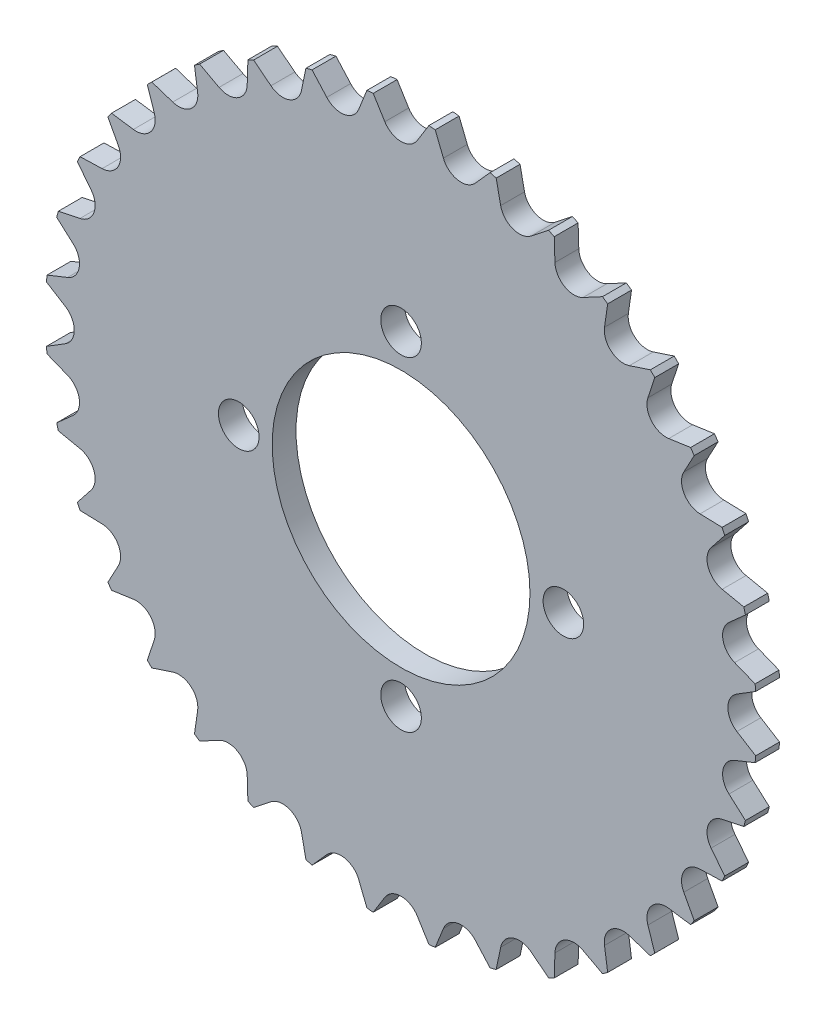
from build123d import *

# Parameters (mm, degrees)
BOSS_EXTRUDE1_DEPTH = 5
SKETCH9_R           = 100
SKETCH9_R_2         = 74.5
CUT_EXTRUDE5_DEPTH  = 10
SKETCH10_R          = 27
SKETCH10_R_2        = 4.25
CUT_EXTRUDE6_DEPTH  = 6


with BuildPart() as part:
    # Sketch1 → Boss-Extrude1 (new body)
    with BuildSketch(Plane.XY):
        with BuildLine():
            ThreePointArc((3.400646872, 70.34391338), (0, 68.45), (-3.400646872, 70.34391338))
            Line((-3.400646872, 70.34391338), (-6.085453124, 74.679004775))
            ThreePointArc((-6.085453124, 74.679004775), (-6.554111855, 74.913841296), (-6.974871672, 74.601190735))
            Line((-6.974871672, 74.601190735), (-8.866108963, 69.865747406))
            ThreePointArc((-8.866108963, 69.865747406), (-11.886217761, 67.410090694), (-15.564075773, 68.684715142))
            Line((-15.564075773, 68.684715142), (-18.960874506, 72.487735044))
            ThreePointArc((-18.960874506, 72.487735044), (-19.463192192, 72.637622137), (-19.823268522, 72.256657264))
            Line((-19.823268522, 72.256657264), (-20.863472565, 67.264746051))
            ThreePointArc((-20.863472565, 67.264746051), (-23.411278811, 64.321959893), (-27.254598108, 64.93856659))
            Line((-27.254598108, 64.93856659), (-31.260179312, 68.093962165))
            ThreePointArc((-31.260179312, 68.093962165), (-31.780893283, 68.154345585), (-32.069345388, 67.716641827))
            Line((-32.069345388, 67.716641827), (-32.226910109, 62.619939425))
            ThreePointArc((-32.226910109, 62.619939425), (-34.225, 59.279438889), (-38.117003271, 59.219292553))
            Line((-38.117003271, 59.219292553), (-42.609659387, 61.631188702))
            ThreePointArc((-42.609659387, 61.631188702), (-43.132948014, 61.600233731), (-43.341011423, 61.119090493))
            Line((-43.341011423, 61.119090493), (-42.611149298, 56.072457626))
            ThreePointArc((-42.611149298, 56.072457626), (-43.998811883, 52.435742131), (-47.821242577, 51.700670278))
            Line((-47.821242577, 51.700670278), (-52.664466523, 53.295782758))
            ThreePointArc((-52.664466523, 53.295782758), (-53.174429945, 53.174429945), (-53.295782758, 52.664466523))
            Line((-53.295782758, 52.664466523), (-51.700670278, 47.821242577))
            ThreePointArc((-51.700670278, 47.821242577), (-52.435742131, 43.998811883), (-56.072457626, 42.611149298))
            Line((-56.072457626, 42.611149298), (-61.119090493, 43.341011423))
            ThreePointArc((-61.119090493, 43.341011423), (-61.600233731, 43.132948014), (-61.631188702, 42.609659387))
            Line((-61.631188702, 42.609659387), (-59.219292553, 38.117003271))
            ThreePointArc((-59.219292553, 38.117003271), (-59.279438889, 34.225), (-62.619939425, 32.226910109))
            Line((-62.619939425, 32.226910109), (-67.716641827, 32.069345388))
            ThreePointArc((-67.716641827, 32.069345388), (-68.154345585, 31.780893283), (-68.093962165, 31.260179312))
            Line((-68.093962165, 31.260179312), (-64.93856659, 27.254598108))
            ThreePointArc((-64.93856659, 27.254598108), (-64.321959893, 23.411278811), (-67.264746051, 20.863472565))
            Line((-67.264746051, 20.863472565), (-72.256657264, 19.823268522))
            ThreePointArc((-72.256657264, 19.823268522), (-72.637622137, 19.463192192), (-72.487735044, 18.960874506))
            Line((-72.487735044, 18.960874506), (-68.684715142, 15.564075773))
            ThreePointArc((-68.684715142, 15.564075773), (-67.410090694, 11.886217761), (-69.865747406, 8.866108963))
            Line((-69.865747406, 8.866108963), (-74.601190735, 6.974871672))
            ThreePointArc((-74.601190735, 6.974871672), (-74.913841296, 6.554111855), (-74.679004775, 6.085453124))
            Line((-74.679004775, 6.085453124), (-70.34391338, 3.400646872))
            ThreePointArc((-70.34391338, 3.400646872), (-68.45, 0), (-70.34391338, -3.400646872))
            Line((-70.34391338, -3.400646872), (-74.679004775, -6.085453124))
            ThreePointArc((-74.679004775, -6.085453124), (-74.913841296, -6.554111855), (-74.601190735, -6.974871672))
            Line((-74.601190735, -6.974871672), (-69.865747406, -8.866108963))
            ThreePointArc((-69.865747406, -8.866108963), (-67.410090694, -11.886217761), (-68.684715142, -15.564075773))
            Line((-68.684715142, -15.564075773), (-72.487735044, -18.960874506))
            ThreePointArc((-72.487735044, -18.960874506), (-72.637622137, -19.463192192), (-72.256657264, -19.823268522))
            Line((-72.256657264, -19.823268522), (-67.264746051, -20.863472565))
            ThreePointArc((-67.264746051, -20.863472565), (-64.321959893, -23.411278811), (-64.93856659, -27.254598108))
            Line((-64.93856659, -27.254598108), (-68.093962165, -31.260179312))
            ThreePointArc((-68.093962165, -31.260179312), (-68.154345585, -31.780893283), (-67.716641827, -32.069345388))
            Line((-67.716641827, -32.069345388), (-62.619939425, -32.226910109))
            ThreePointArc((-62.619939425, -32.226910109), (-59.279438889, -34.225), (-59.219292553, -38.117003271))
            Line((-59.219292553, -38.117003271), (-61.631188702, -42.609659387))
            ThreePointArc((-61.631188702, -42.609659387), (-61.600233731, -43.132948014), (-61.119090493, -43.341011423))
            Line((-61.119090493, -43.341011423), (-56.072457626, -42.611149298))
            ThreePointArc((-56.072457626, -42.611149298), (-52.435742131, -43.998811883), (-51.700670278, -47.821242577))
            Line((-51.700670278, -47.821242577), (-53.295782758, -52.664466523))
            ThreePointArc((-53.295782758, -52.664466523), (-53.174429945, -53.174429945), (-52.664466523, -53.295782758))
            Line((-52.664466523, -53.295782758), (-47.821242577, -51.700670278))
            ThreePointArc((-47.821242577, -51.700670278), (-43.998811883, -52.435742131), (-42.611149298, -56.072457626))
            Line((-42.611149298, -56.072457626), (-43.341011423, -61.119090493))
            ThreePointArc((-43.341011423, -61.119090493), (-43.132948014, -61.600233731), (-42.609659387, -61.631188702))
            Line((-42.609659387, -61.631188702), (-38.117003271, -59.219292553))
            ThreePointArc((-38.117003271, -59.219292553), (-34.225, -59.279438889), (-32.226910109, -62.619939425))
            Line((-32.226910109, -62.619939425), (-32.069345388, -67.716641827))
            ThreePointArc((-32.069345388, -67.716641827), (-31.780893283, -68.154345585), (-31.260179312, -68.093962165))
            Line((-31.260179312, -68.093962165), (-27.254598108, -64.93856659))
            ThreePointArc((-27.254598108, -64.93856659), (-23.411278811, -64.321959893), (-20.863472565, -67.264746051))
            Line((-20.863472565, -67.264746051), (-19.823268522, -72.256657264))
            ThreePointArc((-19.823268522, -72.256657264), (-19.463192192, -72.637622137), (-18.960874506, -72.487735044))
            Line((-18.960874506, -72.487735044), (-15.564075773, -68.684715142))
            ThreePointArc((-15.564075773, -68.684715142), (-11.886217761, -67.410090694), (-8.866108963, -69.865747406))
            Line((-8.866108963, -69.865747406), (-6.974871672, -74.601190735))
            ThreePointArc((-6.974871672, -74.601190735), (-6.554111855, -74.913841296), (-6.085453124, -74.679004775))
            Line((-6.085453124, -74.679004775), (-3.400646872, -70.34391338))
            ThreePointArc((-3.400646872, -70.34391338), (0, -68.45), (3.400646872, -70.34391338))
            Line((3.400646872, -70.34391338), (6.085453124, -74.679004775))
            ThreePointArc((6.085453124, -74.679004775), (6.554111855, -74.913841296), (6.974871672, -74.601190735))
            Line((6.974871672, -74.601190735), (8.866108963, -69.865747406))
            ThreePointArc((8.866108963, -69.865747406), (11.886217761, -67.410090694), (15.564075773, -68.684715142))
            Line((15.564075773, -68.684715142), (18.960874506, -72.487735044))
            ThreePointArc((18.960874506, -72.487735044), (19.463192192, -72.637622137), (19.823268522, -72.256657264))
            Line((19.823268522, -72.256657264), (20.863472565, -67.264746051))
            ThreePointArc((20.863472565, -67.264746051), (23.411278811, -64.321959893), (27.254598108, -64.93856659))
            Line((27.254598108, -64.93856659), (31.260179312, -68.093962165))
            ThreePointArc((31.260179312, -68.093962165), (31.780893283, -68.154345585), (32.069345388, -67.716641827))
            Line((32.069345388, -67.716641827), (32.226910109, -62.619939425))
            ThreePointArc((32.226910109, -62.619939425), (34.225, -59.279438889), (38.117003271, -59.219292553))
            Line((38.117003271, -59.219292553), (42.609659387, -61.631188702))
            ThreePointArc((42.609659387, -61.631188702), (43.132948014, -61.600233731), (43.341011423, -61.119090493))
            Line((43.341011423, -61.119090493), (42.611149298, -56.072457626))
            ThreePointArc((42.611149298, -56.072457626), (43.998811883, -52.435742131), (47.821242577, -51.700670278))
            Line((47.821242577, -51.700670278), (52.664466523, -53.295782758))
            ThreePointArc((52.664466523, -53.295782758), (53.174429945, -53.174429945), (53.295782758, -52.664466523))
            Line((53.295782758, -52.664466523), (51.700670278, -47.821242577))
            ThreePointArc((51.700670278, -47.821242577), (52.435742131, -43.998811883), (56.072457626, -42.611149298))
            Line((56.072457626, -42.611149298), (61.119090493, -43.341011423))
            ThreePointArc((61.119090493, -43.341011423), (61.600233731, -43.132948014), (61.631188702, -42.609659387))
            Line((61.631188702, -42.609659387), (59.219292553, -38.117003271))
            ThreePointArc((59.219292553, -38.117003271), (59.279438889, -34.225), (62.619939425, -32.226910109))
            Line((62.619939425, -32.226910109), (67.716641827, -32.069345388))
            ThreePointArc((67.716641827, -32.069345388), (68.154345585, -31.780893283), (68.093962165, -31.260179312))
            Line((68.093962165, -31.260179312), (64.93856659, -27.254598108))
            ThreePointArc((64.93856659, -27.254598108), (64.321959893, -23.411278811), (67.264746051, -20.863472565))
            Line((67.264746051, -20.863472565), (72.256657264, -19.823268522))
            ThreePointArc((72.256657264, -19.823268522), (72.637622137, -19.463192192), (72.487735044, -18.960874506))
            Line((72.487735044, -18.960874506), (68.684715142, -15.564075773))
            ThreePointArc((68.684715142, -15.564075773), (67.410090694, -11.886217761), (69.865747406, -8.866108963))
            Line((69.865747406, -8.866108963), (74.601190735, -6.974871672))
            ThreePointArc((74.601190735, -6.974871672), (74.913841296, -6.554111855), (74.679004775, -6.085453124))
            Line((74.679004775, -6.085453124), (70.34391338, -3.400646872))
            ThreePointArc((70.34391338, -3.400646872), (68.45, 0), (70.34391338, 3.400646872))
            Line((70.34391338, 3.400646872), (74.679004775, 6.085453124))
            ThreePointArc((74.679004775, 6.085453124), (74.913841296, 6.554111855), (74.601190735, 6.974871672))
            Line((74.601190735, 6.974871672), (69.865747406, 8.866108963))
            ThreePointArc((69.865747406, 8.866108963), (67.410090694, 11.886217761), (68.684715142, 15.564075773))
            Line((68.684715142, 15.564075773), (72.487735044, 18.960874506))
            ThreePointArc((72.487735044, 18.960874506), (72.637622137, 19.463192192), (72.256657264, 19.823268522))
            Line((72.256657264, 19.823268522), (67.264746051, 20.863472565))
            ThreePointArc((67.264746051, 20.863472565), (64.321959893, 23.411278811), (64.93856659, 27.254598108))
            Line((64.93856659, 27.254598108), (68.093962165, 31.260179312))
            ThreePointArc((68.093962165, 31.260179312), (68.154345585, 31.780893283), (67.716641827, 32.069345388))
            Line((67.716641827, 32.069345388), (62.619939425, 32.226910109))
            ThreePointArc((62.619939425, 32.226910109), (59.279438889, 34.225), (59.219292553, 38.117003271))
            Line((59.219292553, 38.117003271), (61.631188702, 42.609659387))
            ThreePointArc((61.631188702, 42.609659387), (61.600233731, 43.132948014), (61.119090493, 43.341011423))
            Line((61.119090493, 43.341011423), (56.072457626, 42.611149298))
            ThreePointArc((56.072457626, 42.611149298), (52.435742131, 43.998811883), (51.700670278, 47.821242577))
            Line((51.700670278, 47.821242577), (53.295782758, 52.664466523))
            ThreePointArc((53.295782758, 52.664466523), (53.174429945, 53.174429945), (52.664466523, 53.295782758))
            Line((52.664466523, 53.295782758), (47.821242577, 51.700670278))
            ThreePointArc((47.821242577, 51.700670278), (43.998811883, 52.435742131), (42.611149298, 56.072457626))
            Line((42.611149298, 56.072457626), (43.341011423, 61.119090493))
            ThreePointArc((43.341011423, 61.119090493), (43.132948014, 61.600233731), (42.609659387, 61.631188702))
            Line((42.609659387, 61.631188702), (38.117003271, 59.219292553))
            ThreePointArc((38.117003271, 59.219292553), (34.225, 59.279438889), (32.226910109, 62.619939425))
            Line((32.226910109, 62.619939425), (32.069345388, 67.716641827))
            ThreePointArc((32.069345388, 67.716641827), (31.780893283, 68.154345585), (31.260179312, 68.093962165))
            Line((31.260179312, 68.093962165), (27.254598108, 64.93856659))
            ThreePointArc((27.254598108, 64.93856659), (23.411278811, 64.321959893), (20.863472565, 67.264746051))
            Line((20.863472565, 67.264746051), (19.823268522, 72.256657264))
            ThreePointArc((19.823268522, 72.256657264), (19.463192192, 72.637622137), (18.960874506, 72.487735044))
            Line((18.960874506, 72.487735044), (15.564075773, 68.684715142))
            ThreePointArc((15.564075773, 68.684715142), (11.886217761, 67.410090694), (8.866108963, 69.865747406))
            Line((8.866108963, 69.865747406), (6.974871672, 74.601190735))
            ThreePointArc((6.974871672, 74.601190735), (6.554111855, 74.913841296), (6.085453124, 74.679004775))
            Line((6.085453124, 74.679004775), (3.400646872, 70.34391338))
        make_face()
    extrude(amount=BOSS_EXTRUDE1_DEPTH)

    # Sketch9 → Cut-Extrude5 (cut)
    with BuildSketch(Plane(origin=(0, 0, 0), x_dir=(-1, 0, 0), z_dir=(0, 0, -1))):
        Circle(SKETCH9_R)
        Circle(SKETCH9_R_2, mode=Mode.SUBTRACT)
    extrude(amount=-CUT_EXTRUDE5_DEPTH, mode=Mode.SUBTRACT)

    # Sketch10 → Cut-Extrude6 (cut, through all)
    with BuildSketch(Plane.XY.offset(5)):
        Circle(SKETCH10_R)
        with Locations((0, 34)):
            Circle(SKETCH10_R_2)
        with Locations((34, 0)):
            Circle(SKETCH10_R_2)
        with Locations((0, -34)):
            Circle(SKETCH10_R_2)
        with Locations((-34, 0)):
            Circle(SKETCH10_R_2)
    extrude(amount=-CUT_EXTRUDE6_DEPTH, mode=Mode.SUBTRACT)


solid = part.part
